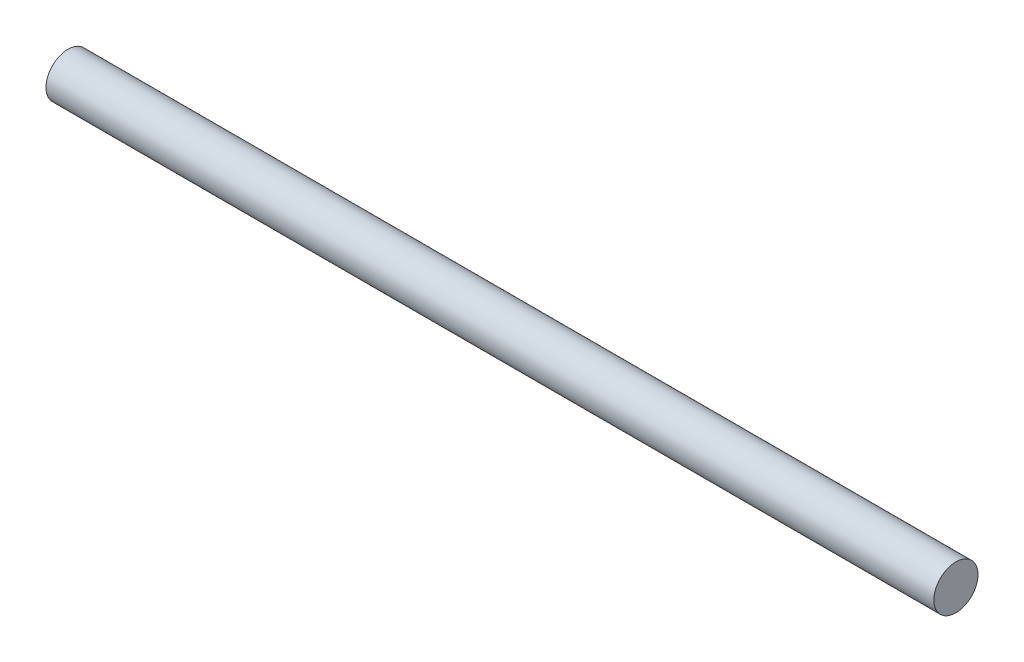
from build123d import *

# Parameters (mm, degrees)
SKETCH3_R           = 1.5
BOSS_EXTRUDE1_DEPTH = 30.15


with BuildPart() as part:
    # Sketch3 → Boss-Extrude1 (new body, symmetric)
    with BuildSketch(Plane(origin=(0, 0, 0), x_dir=(0, 0, -1), z_dir=(1, 0, 0))):
        Circle(SKETCH3_R)
    extrude(amount=BOSS_EXTRUDE1_DEPTH, both=True)


solid = part.part
